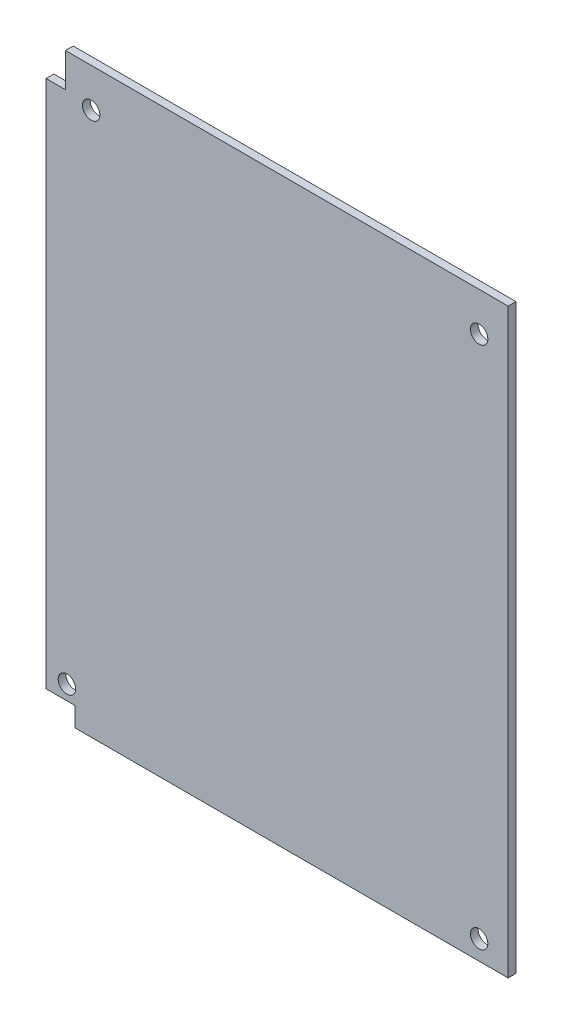
from build123d import *

# Parameters (mm, degrees)
SKETCH_2_W          = 95.3
SKETCH_2_H          = 120
EXTRUDE_2_DEPTH     = 1.6
SKETCH_3_R          = 1.8
SKETCH_3_W          = 4
SKETCH_3_H          = 7
SKETCH_3_W_2        = 6
SKETCH_3_H_2        = 4
CUT_EXTRUDE_1_DEPTH = 2.6


with BuildPart() as part:
    # 스케치2 → 보스-돌출2 (new body)
    with BuildSketch(Plane.XY):
        Rectangle(SKETCH_2_W, SKETCH_2_H)
    extrude(amount=EXTRUDE_2_DEPTH)

    # 스케치3 → 컷-돌출1 (cut, through all)
    with BuildSketch(Plane.XY.offset(1.6)):
        with Locations((-38.35, 52)):
            Circle(SKETCH_3_R)
        with Locations((41.65, 52)):
            Circle(SKETCH_3_R)
        with Locations((41.65, -56)):
            Circle(SKETCH_3_R)
        with Locations((-43.35, -53)):
            Circle(SKETCH_3_R)
        with Locations((-45.65, 56.5)):
            Rectangle(SKETCH_3_W, SKETCH_3_H)
        with Locations((-44.65, -58)):
            Rectangle(SKETCH_3_W_2, SKETCH_3_H_2)
    extrude(amount=-CUT_EXTRUDE_1_DEPTH, mode=Mode.SUBTRACT)


solid = part.part
